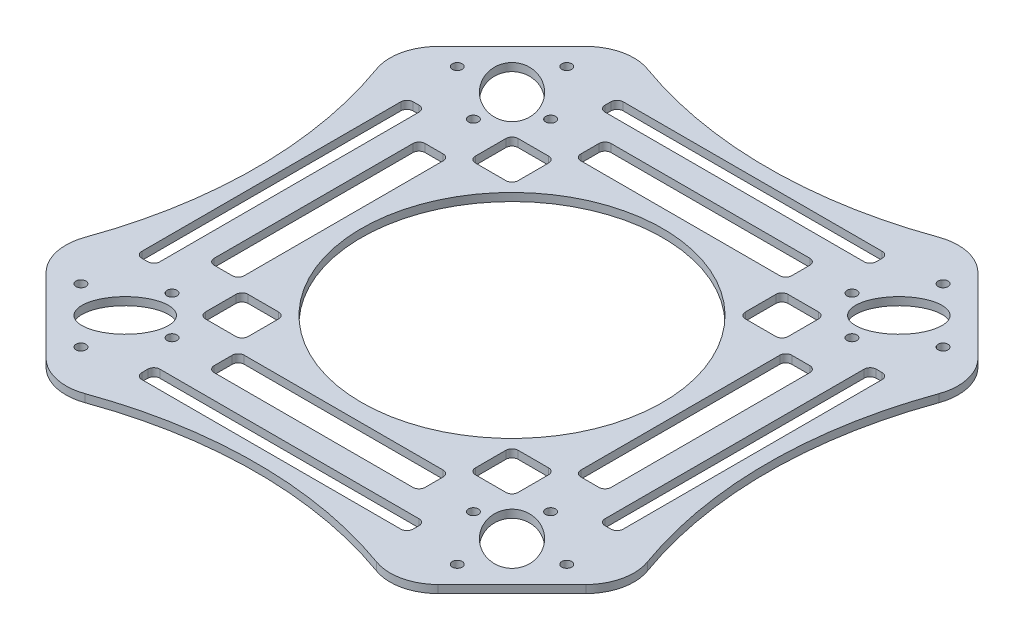
from build123d import *

# Parameters (mm, degrees)
BOSS_EXTRUDE1_DEPTH = 1.5
SCALE1_SCALE        = 2.22222
SKETCH2_R           = 2.083333273
SKETCH2_R_2         = 63.5
SKETCH2_RX          = 15.277777674
SKETCH2_RY          = 9.72222211
CUT_EXTRUDE1_DEPTH  = 4.33333
FILLET1_R           = 20.32
SKETCH3_W           = 12.7
SKETCH3_H           = 88.9
SKETCH3_W_2         = 114.3
SKETCH3_H_2         = 7.62
SKETCH3_W_3         = 88.9
SKETCH3_H_3         = 12.7
SKETCH3_W_4         = 7.62
SKETCH3_H_4         = 114.3
CUT_EXTRUDE2_DEPTH  = 4.3333301
FILLET2_R           = 2.54
SKETCH4_W           = 17.960512242
SKETCH4_H           = 17.960512242
CUT_EXTRUDE3_DEPTH  = 4.3333301
FILLET3_R           = 2.54


with BuildPart() as part:
    # Sketch1 → Boss-Extrude1 (new body)
    with BuildSketch(Plane(origin=(0, 0, 0), x_dir=(1, 0, 0), z_dir=(0, 1, 0))):
        with BuildLine():
            Line((0, 0), (0, 48.5))
            ThreePointArc((0, 48.5), (-16.831099363, 50.256886854), (-32.93654628, 55.451801369))
            Line((-32.93654628, 55.451801369), (-55.451801369, 32.93654628))
            ThreePointArc((-55.451801369, 32.93654628), (-48.5, 0), (-55.451801369, -32.93654628))
            Line((-55.451801369, -32.93654628), (-32.93654628, -55.451801369))
            ThreePointArc((-32.93654628, -55.451801369), (0, -48.5), (32.93654628, -55.451801369))
            Line((32.93654628, -55.451801369), (55.451801369, -32.93654628))
            ThreePointArc((55.451801369, -32.93654628), (50.256886854, -16.831099363), (48.5, 0))
            Line((48.5, 0), (0, 0))
        make_face()
        with BuildLine():
            Line((44.194173824, 44.194173824), (32.93654628, 55.451801369))
            ThreePointArc((32.93654628, 55.451801369), (16.831099363, 50.256886854), (0, 48.5))
            Line((0, 48.5), (0, 0))
            Line((0, 0), (44.194173824, 44.194173824))
        make_face()
        with BuildLine():
            Line((55.451801369, 32.93654628), (44.194173824, 44.194173824))
            Line((44.194173824, 44.194173824), (0, 0))
            Line((0, 0), (48.5, 0))
            ThreePointArc((48.5, 0), (50.256886854, 16.831099363), (55.451801369, 32.93654628))
        make_face()
    extrude(amount=BOSS_EXTRUDE1_DEPTH)


with BuildPart() as part_1:
    # Scale1: scaled about (0, 0.75, 0)
    add(part.part.scale(SCALE1_SCALE).moved(Location((0, -0.916665, 0))))

    # Sketch2 → Cut-Extrude1 (cut, through all)
    with BuildSketch(Plane(origin=(0, 2.416665, 0), x_dir=(1, 0, 0), z_dir=(0, 1, 0))):
        with Locations((63.508194546, 79.78705449)):
            Circle(SKETCH2_R)
        with Locations((79.303891553, 102.383071198)):
            Circle(SKETCH2_R)
        with Locations((79.78705449, 63.508194546)):
            Circle(SKETCH2_R)
        with Locations((102.383071198, 79.303891553)):
            Circle(SKETCH2_R)
        Circle(SKETCH2_R_2)
        with Locations((102.383071198, -79.30406833)):
            Circle(SKETCH2_R)
        with Locations((79.303891553, -102.383247975)):
            Circle(SKETCH2_R)
        with Locations((63.508194546, -79.787231267)):
            Circle(SKETCH2_R)
        with Locations((79.78705449, -63.508371323)):
            Circle(SKETCH2_R)
        with Locations((-79.30406833, -102.383247975)):
            Circle(SKETCH2_R)
        with Locations((-102.383247975, -79.30406833)):
            Circle(SKETCH2_R)
        with Locations((-79.787231267, -63.508371323)):
            Circle(SKETCH2_R)
        with Locations((-63.508371323, -79.787231267)):
            Circle(SKETCH2_R)
        with Locations((-102.383247975, 79.303891553)):
            Circle(SKETCH2_R)
        with Locations((-79.30406833, 102.383071198)):
            Circle(SKETCH2_R)
        with Locations((-63.508371323, 79.78705449)):
            Circle(SKETCH2_R)
        with Locations((-79.787231267, 63.508194546)):
            Circle(SKETCH2_R)
        with Locations(Location((81.513600242, -81.513777019), (0, 0, -45))):
            Ellipse(SKETCH2_RX, SKETCH2_RY)
        with Locations(Location((81.513600242, 81.513600242), (0, 0, 45))):
            Ellipse(SKETCH2_RX, SKETCH2_RY)
        with Locations(Location((-81.513777019, -81.513777019), (0, 0, -135))):
            Ellipse(SKETCH2_RX, SKETCH2_RY)
        with Locations(Location((-81.513777019, 81.513600242), (0, 0, 135))):
            Ellipse(SKETCH2_RX, SKETCH2_RY)
    extrude(amount=-CUT_EXTRUDE1_DEPTH, mode=Mode.SUBTRACT)

    # Fillet1
    fillet1_edges = [part_1.edges().sort_by_distance(p)[0] for p in [
        (123.226102038, 0.75, 73.192251873),
        (73.192251873, 0.75, 123.226102038),
        (-73.192251873, 0.75, 123.226102038),
        (-123.226102038, 0.75, 73.192251873),
        (-123.226102038, 0.75, -73.192251873),
        (-73.192251873, 0.75, -123.226102038),
        (73.192251873, 0.75, -123.226102038),
        (123.226102038, 0.75, -73.192251873),
    ]]
    fillet(fillet1_edges, radius=FILLET1_R)

    # Sketch3 → Cut-Extrude2 (cut, through all)
    with BuildSketch(Plane(origin=(0, 2.416665, 0), x_dir=(1, 0, 0), z_dir=(0, 1, 0))):
        with Locations((77.29767, 0)):
            Rectangle(SKETCH3_W, SKETCH3_H)
        with Locations((0, 97.61767)):
            Rectangle(SKETCH3_W_2, SKETCH3_H_2)
        with Locations((0, 77.29767)):
            Rectangle(SKETCH3_W_3, SKETCH3_H_3)
        with Locations((97.61767, 0)):
            Rectangle(SKETCH3_W_4, SKETCH3_H_4)
        with Locations((0, -77.29767)):
            Rectangle(SKETCH3_W_3, SKETCH3_H_3)
        with Locations((0, -97.61767)):
            Rectangle(SKETCH3_W_2, SKETCH3_H_2)
        with Locations((-77.29767, 0)):
            Rectangle(SKETCH3_W, SKETCH3_H)
        with Locations((-97.61767, 0)):
            Rectangle(SKETCH3_W_4, SKETCH3_H_4)
    extrude(amount=-CUT_EXTRUDE2_DEPTH, mode=Mode.SUBTRACT)

    # Fillet2
    fillet2_edges = [part_1.edges().sort_by_distance(p)[0] for p in [
        (57.15, 0.75, -101.42767),
        (57.15, 0.75, -93.80767),
        (-57.15, 0.75, -93.80767),
        (-57.15, 0.75, -101.42767),
        (-44.45, 0.75, 83.64767),
        (-44.45, 0.75, 70.94767),
        (44.45, 0.75, 70.94767),
        (44.45, 0.75, 83.64767),
        (-101.42767, 0.75, 57.15),
        (-101.42767, 0.75, -57.15),
        (-93.80767, 0.75, -57.15),
        (-93.80767, 0.75, 57.15),
        (-83.64767, 0.75, -44.45),
        (-70.94767, 0.75, -44.45),
        (-70.94767, 0.75, 44.45),
        (-83.64767, 0.75, 44.45),
        (44.45, 0.75, -83.64767),
        (44.45, 0.75, -70.94767),
        (-44.45, 0.75, -70.94767),
        (-44.45, 0.75, -83.64767),
        (101.42767, 0.75, -57.15),
        (101.42767, 0.75, 57.15),
        (93.80767, 0.75, 57.15),
        (93.80767, 0.75, -57.15),
        (83.64767, 0.75, 44.45),
        (70.94767, 0.75, 44.45),
        (70.94767, 0.75, -44.45),
        (83.64767, 0.75, -44.45),
        (57.15, 0.75, 101.42767),
        (-57.15, 0.75, 101.42767),
        (-57.15, 0.75, 93.80767),
        (57.15, 0.75, 93.80767),
    ]]
    fillet(fillet2_edges, radius=FILLET2_R)

    # Sketch4 → Cut-Extrude3 (cut, through all)
    with BuildSketch(Plane(origin=(0, 2.416665, 0), x_dir=(1, 0, 0), z_dir=(0, 1, 0))):
        with Locations((56.899998799, -56.899998799)):
            Rectangle(SKETCH4_W, SKETCH4_H)
        with Locations((56.899998799, 56.899998799)):
            Rectangle(SKETCH4_W, SKETCH4_H)
        with Locations((-56.899998799, -56.899998799)):
            Rectangle(SKETCH4_W, SKETCH4_H)
        with Locations((-56.899998799, 56.899998799)):
            Rectangle(SKETCH4_W, SKETCH4_H)
    extrude(amount=-CUT_EXTRUDE3_DEPTH, mode=Mode.SUBTRACT)

    # Fillet3
    fillet3_edges = [part_1.edges().sort_by_distance(p)[0] for p in [
        (-65.88025492, 0.75, -65.88025492),
        (-47.919742678, 0.75, -65.88025492),
        (-47.919742678, 0.75, -47.919742678),
        (-65.88025492, 0.75, -47.919742678),
        (-65.88025492, 0.75, 65.88025492),
        (-65.88025492, 0.75, 47.919742678),
        (-47.919742678, 0.75, 47.919742678),
        (-47.919742678, 0.75, 65.88025492),
        (65.88025492, 0.75, 65.88025492),
        (47.919742678, 0.75, 65.88025492),
        (47.919742678, 0.75, 47.919742678),
        (65.88025492, 0.75, 47.919742678),
        (65.88025492, 0.75, -65.88025492),
        (65.88025492, 0.75, -47.919742678),
        (47.919742678, 0.75, -47.919742678),
        (47.919742678, 0.75, -65.88025492),
    ]]
    fillet(fillet3_edges, radius=FILLET3_R)


solid = part_1.part
